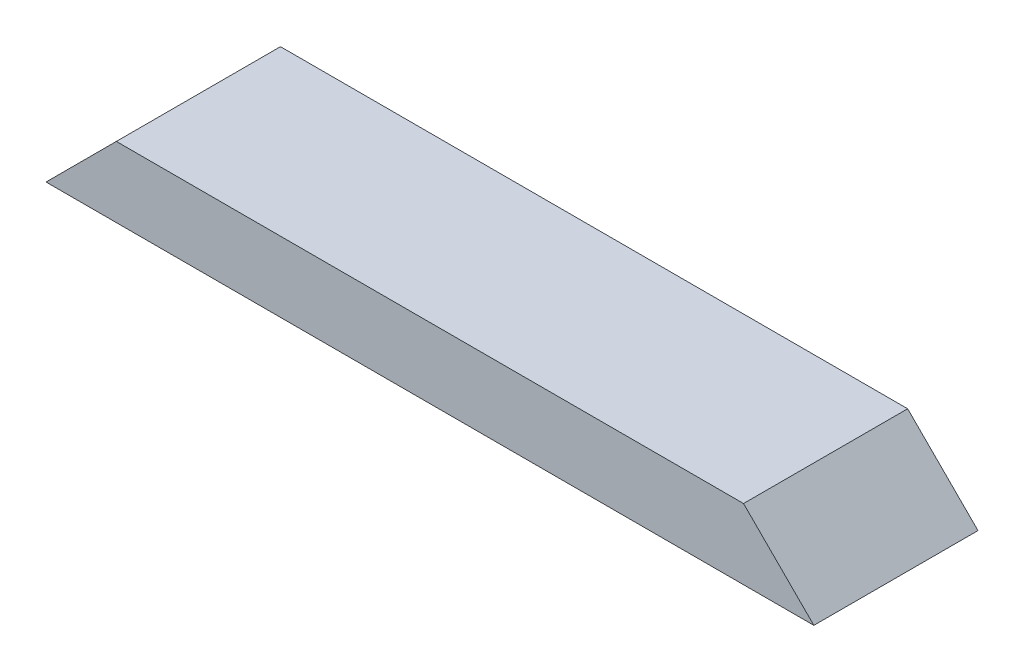
from build123d import *

# Parameters (mm, degrees)
SKETCH1_W           = 415.925
SKETCH1_H           = 88.9
BOSS_EXTRUDE1_DEPTH = 38.1
CUT_EXTRUDE1_DEPTH  = 89.9


with BuildPart() as part:
    # Sketch1 → Boss-Extrude1 (new body)
    with BuildSketch(Plane(origin=(0, 0, 0), x_dir=(1, 0, 0), z_dir=(0, 1, 0))):
        with Locations((207.9625, 44.45)):
            Rectangle(SKETCH1_W, SKETCH1_H)
    extrude(amount=BOSS_EXTRUDE1_DEPTH)

    # Sketch2 → Cut-Extrude1 (cut, through all)
    with BuildSketch(Plane.XY):
        Polygon((0, 0), (38.1, 38.1), (0, 38.1), align=None)
        Polygon((415.925, 0), (415.925, 38.1), (377.825, 38.1), align=None)
    extrude(amount=-CUT_EXTRUDE1_DEPTH, mode=Mode.SUBTRACT)


solid = part.part
